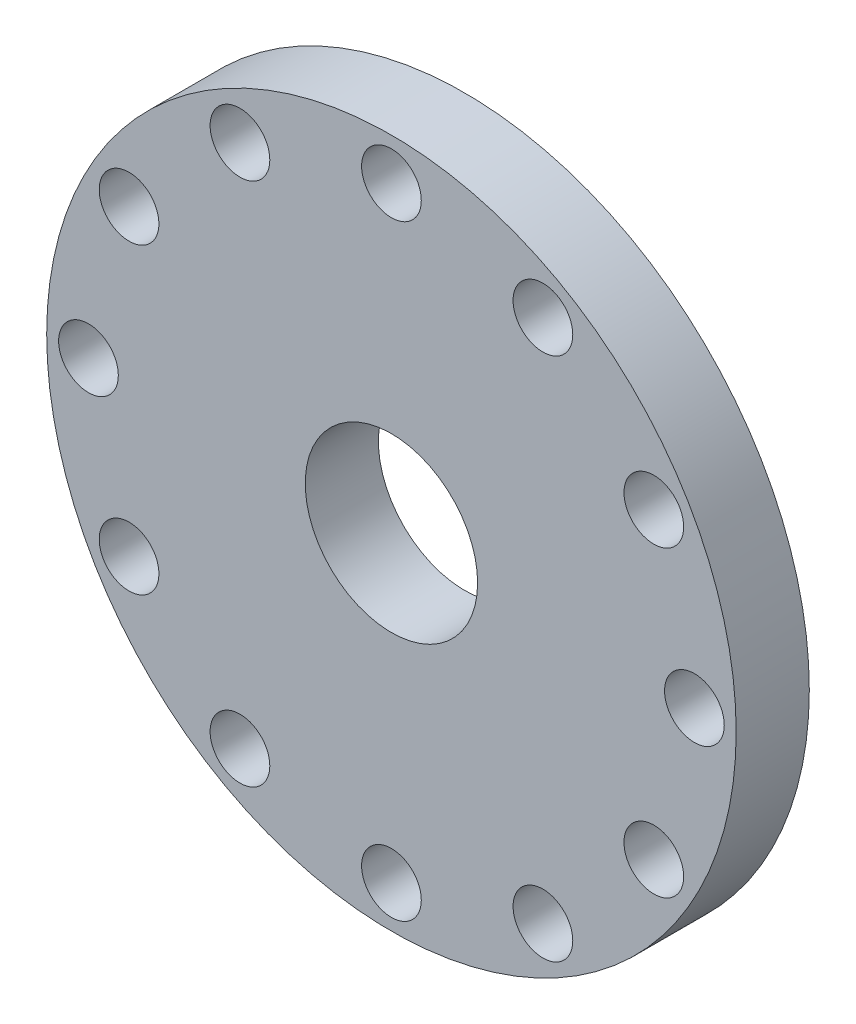
from build123d import *

# Parameters (mm, degrees)
SKETCH1_R           = 330
SKETCH1_R_2         = 82.5
BOSS_EXTRUDE1_DEPTH = 70
SKETCH2_R           = 28.575
CUT_EXTRUDE1_DEPTH  = 131


with BuildPart() as part:
    # Sketch1 → Boss-Extrude1 (new body)
    with BuildSketch(Plane.XY):
        Circle(SKETCH1_R)
        Circle(SKETCH1_R_2, mode=Mode.SUBTRACT)
    extrude(amount=BOSS_EXTRUDE1_DEPTH)

    # Sketch2 → Cut-Extrude1 (cut)
    with BuildSketch(Plane.XY):
        with Locations((0, 290)):
            Circle(SKETCH2_R)
        with Locations((145, 251.147367097)):
            Circle(SKETCH2_R)
        with Locations((251.147367097, 145)):
            Circle(SKETCH2_R)
        with Locations((290, 0)):
            Circle(SKETCH2_R)
        with Locations((251.147367098, -145)):
            Circle(SKETCH2_R)
        with Locations((145, -251.147367097)):
            Circle(SKETCH2_R)
        with Locations((0, -290)):
            Circle(SKETCH2_R)
        with Locations((-145, -251.147367097)):
            Circle(SKETCH2_R)
        with Locations((-251.147367097, -145)):
            Circle(SKETCH2_R)
        with Locations((-290, 0)):
            Circle(SKETCH2_R)
        with Locations((-251.147367097, 145)):
            Circle(SKETCH2_R)
        with Locations((-145, 251.147367097)):
            Circle(SKETCH2_R)
    extrude(amount=CUT_EXTRUDE1_DEPTH, mode=Mode.SUBTRACT)


solid = part.part
